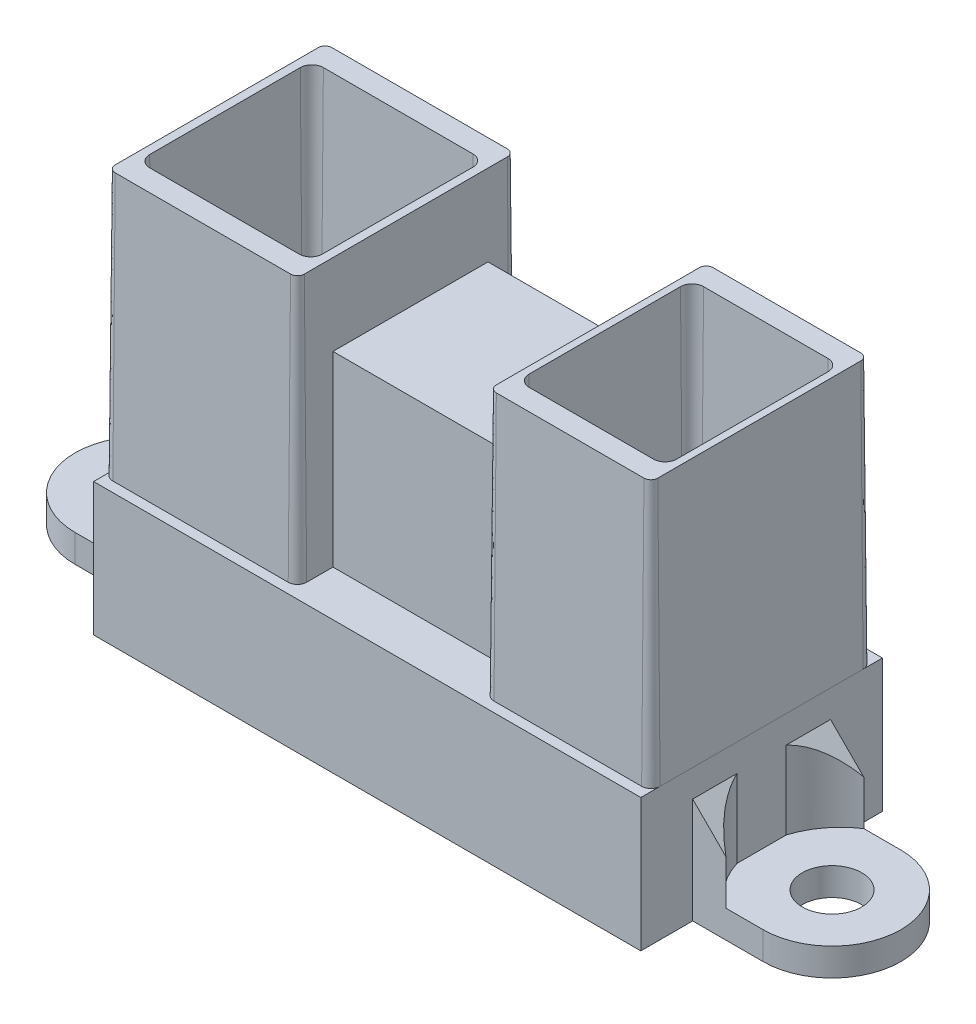
from build123d import *

# Parameters (mm, degrees)
BOSS_EXTRUDE1_DEPTH     = 7.2
SKETCH2_R               = 1.61
BOSS_EXTRUDE2_DEPTH     = 1.5
BOSS_EXTRUDE3_DEPTH     = 0.7
BOSS_EXTRUDE4_DEPTH     = 14.4
BOSS_EXTRUDE4_TAPER     = 0.5
SKETCH5_W               = 10.15
SKETCH5_H               = 8.4
BOSS_EXTRUDE5_DEPTH     = 10.12
SKETCH6_W               = 10.15
SKETCH6_H               = 5.5
BOSS_EXTRUDE6_DEPTH     = 6.35
BOSS_EXTRUDE7_DEPTH     = 4.22
CUT_EXTRUDE1_DEPTH      = 7.544999991
CUT_EXTRUDE1_DEPTH_BACK = 10.824999991
SKETCH9_W               = 27.11
SKETCH9_H               = 10.549999982
BOSS_EXTRUDE8_DEPTH     = 1.2


with BuildPart() as part:
    # Sketch1 → Boss-Extrude1 (new body)
    with BuildSketch(Plane(origin=(0, 0, 0), x_dir=(1, 0, 0), z_dir=(0, 1, 0))):
        Polygon((-14.055, 5.774999991), (-5.355, 5.774999991), (-5.355, 6.544999991), (-14.825, 6.544999991), (-14.825, -6.544999991), (14.825, -6.544999991), (14.825, 6.544999991), (5.355, 6.544999991), (5.355, 5.774999991), (14.055, 5.774999991), (14.055, -5.774999991), (-14.055, -5.774999991), align=None)
    extrude(amount=BOSS_EXTRUDE1_DEPTH)

    # Sketch2 → Boss-Extrude2 (add)
    with BuildSketch(Plane(origin=(0, 0, 0), x_dir=(1, 0, 0), z_dir=(0, 1, 0))):
        with BuildLine():
            Line((18.64, 3.735), (14.825, 3.735))
            Line((14.825, 3.735), (14.825, -3.735))
            Line((14.825, -3.735), (18.64, -3.735))
            ThreePointArc((18.64, -3.735), (22.375, 0), (18.64, 3.735))
        make_face()
        with Locations((18.64, 0)):
            Circle(SKETCH2_R, mode=Mode.SUBTRACT)
        with BuildLine():
            Line((-14.825, 3.735), (-14.825, -3.735))
            Line((-14.825, -3.735), (-18.64, -3.735))
            ThreePointArc((-18.64, -3.735), (-22.375, 0), (-18.64, 3.735))
            Line((-18.64, 3.735), (-14.825, 3.735))
        make_face()
        with Locations((-18.64, 0)):
            Circle(SKETCH2_R, mode=Mode.SUBTRACT)
    extrude(amount=BOSS_EXTRUDE2_DEPTH)

    # Sketch3 → Boss-Extrude3 (add)
    with BuildSketch(Plane(origin=(0, 7.2, 0), x_dir=(1, 0, 0), z_dir=(0, 1, 0))):
        Polygon((-14.825, -6.544999991), (14.825, -6.544999991), (14.825, 6.544999991), (5.355, 6.544999991), (5.355, 4.324999991), (-5.355, 4.324999991), (-5.355, 6.544999991), (-14.825, 6.544999991), align=None)
    extrude(amount=-BOSS_EXTRUDE3_DEPTH)

    # Sketch4 → Boss-Extrude4 (add)
    with BuildSketch(Plane(origin=(0, 7.2, 0), x_dir=(1, 0, 0), z_dir=(0, 1, 0))):
        with BuildLine():
            Line((-14.325, -6), (-4.825, -6))
            ThreePointArc((-4.825, -6), (-4.471446609, -5.853553391), (-4.325, -5.5))
            Line((-4.325, -5.5), (-4.325, 5.5))
            ThreePointArc((-4.325, 5.5), (-4.471446609, 5.853553391), (-4.825, 6))
            Line((-4.825, 6), (-14.325, 6))
            ThreePointArc((-14.325, 6), (-14.678553391, 5.853553391), (-14.825, 5.5))
            Line((-14.825, 5.5), (-14.825, -5.5))
            ThreePointArc((-14.825, -5.5), (-14.678553391, -5.853553391), (-14.325, -6))
        make_face()
        with BuildLine():
            Line((-13.625, -4.58), (-5.525, -4.58))
            ThreePointArc((-5.525, -4.58), (-5.171446609, -4.433553391), (-5.025, -4.08))
            Line((-5.025, -4.08), (-5.025, 4.08))
            ThreePointArc((-5.025, 4.08), (-5.171446609, 4.433553391), (-5.525, 4.58))
            Line((-5.525, 4.58), (-13.625, 4.58))
            ThreePointArc((-13.625, 4.58), (-13.978553391, 4.433553391), (-14.125, 4.08))
            Line((-14.125, 4.08), (-14.125, -4.08))
            ThreePointArc((-14.125, -4.08), (-13.978553391, -4.433553391), (-13.625, -4.58))
        make_face(mode=Mode.SUBTRACT)
        with BuildLine():
            Line((6.325, -6), (14.325, -6))
            ThreePointArc((14.325, -6), (14.678553391, -5.853553391), (14.825, -5.5))
            Line((14.825, -5.5), (14.825, 5.5))
            ThreePointArc((14.825, 5.5), (14.678553391, 5.853553391), (14.325, 6))
            Line((14.325, 6), (6.325, 6))
            ThreePointArc((6.325, 6), (5.971446609, 5.853553391), (5.825, 5.5))
            Line((5.825, 5.5), (5.825, -5.5))
            ThreePointArc((5.825, -5.5), (5.971446609, -5.853553391), (6.325, -6))
        make_face()
        with BuildLine():
            Line((6.955, -4.6), (13.695, -4.6))
            ThreePointArc((13.695, -4.6), (14.048553391, -4.453553391), (14.195, -4.1))
            Line((14.195, -4.1), (14.195, 4.1))
            ThreePointArc((14.195, 4.1), (14.048553391, 4.453553391), (13.695, 4.6))
            Line((13.695, 4.6), (6.955, 4.6))
            ThreePointArc((6.955, 4.6), (6.601446609, 4.453553391), (6.455, 4.1))
            Line((6.455, 4.1), (6.455, -4.1))
            ThreePointArc((6.455, -4.1), (6.601446609, -4.453553391), (6.955, -4.6))
        make_face(mode=Mode.SUBTRACT)
    extrude(amount=BOSS_EXTRUDE4_DEPTH, taper=BOSS_EXTRUDE4_TAPER)

    # Sketch5 → Boss-Extrude5 (add)
    with BuildSketch(Plane(origin=(0, 7.2, 0), x_dir=(1, 0, 0), z_dir=(0, 1, 0))):
        with Locations((0.75, 0.124999991)):
            Rectangle(SKETCH5_W, SKETCH5_H)
    extrude(amount=BOSS_EXTRUDE5_DEPTH)

    # Sketch6 → Boss-Extrude6 (add)
    with BuildSketch(Plane(origin=(0, 3.37, 0), x_dir=(1, 0, 0), z_dir=(0, 1, 0))):
        with Locations((0, 7.074999991)):
            Rectangle(SKETCH6_W, SKETCH6_H)
    extrude(amount=BOSS_EXTRUDE6_DEPTH)

    # Sketch7 → Boss-Extrude7 (add)
    with BuildSketch(Plane(origin=(0, 1.5, 0), x_dir=(1, 0, 0), z_dir=(0, 1, 0))):
        with BuildLine():
            Line((-14.825, 3.735), (-16.625, 3.735))
            ThreePointArc((-16.625, 3.735), (-15.518302355, 2.690023234), (-14.825, 1.335))
            Line((-14.825, 1.335), (-14.825, 3.735))
        make_face()
        with BuildLine():
            Line((-14.825, -3.735), (-14.825, -1.335))
            ThreePointArc((-14.825, -1.335), (-15.518302355, -2.690023234), (-16.625, -3.735))
            Line((-16.625, -3.735), (-14.825, -3.735))
        make_face()
        with BuildLine():
            Line((14.825, -3.735), (16.625, -3.735))
            ThreePointArc((16.625, -3.735), (15.518302355, -2.690023234), (14.825, -1.335))
            Line((14.825, -1.335), (14.825, -3.735))
        make_face()
        with BuildLine():
            Line((14.825, 3.735), (14.825, 1.335))
            ThreePointArc((14.825, 1.335), (15.518302355, 2.690023234), (16.625, 3.735))
            Line((16.625, 3.735), (14.825, 3.735))
        make_face()
    extrude(amount=BOSS_EXTRUDE7_DEPTH)

    # Sketch8 → Cut-Extrude1 (cut, two sides)
    with BuildSketch(Plane.XY) as cut_extrude1_sk:
        Polygon((-14.825, 5.72), (-16.625, 3.92), (-16.625, 5.72), align=None)
        Polygon((14.825, 5.72), (16.625, 3.92), (16.625, 5.72), align=None)
    extrude(amount=CUT_EXTRUDE1_DEPTH, mode=Mode.SUBTRACT)
    extrude(cut_extrude1_sk.sketch, amount=-CUT_EXTRUDE1_DEPTH_BACK, mode=Mode.SUBTRACT)

    # Sketch9 → Boss-Extrude8 (add)
    with BuildSketch(Plane.XZ.offset(-3.37)):
        Rectangle(SKETCH9_W, SKETCH9_H)
    extrude(amount=-BOSS_EXTRUDE8_DEPTH)


solid = part.part
